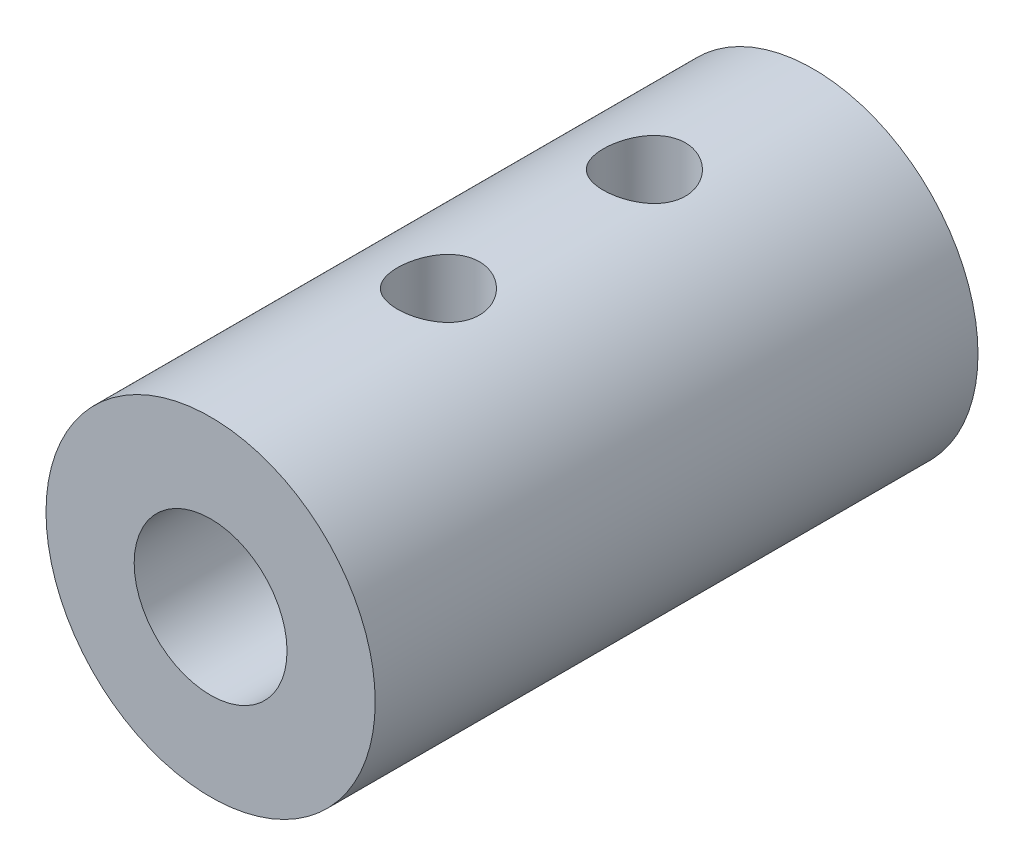
from build123d import *

# Parameters (mm, degrees)
SKETCH1_R                = 5.6
SKETCH1_R_2              = 2.6
BOSS_EXTRUDE1_DEPTH      = 11.508
BOSS_EXTRUDE1_DEPTH_BACK = 9
SKETCH3_R                = 1.397
CUT_EXTRUDE2_DEPTH       = 6.6


with BuildPart() as part:
    # Sketch1 → Boss-Extrude1 (new body, two sides)
    with BuildSketch(Plane.XY) as boss_extrude1_sk:
        Circle(SKETCH1_R)
        Circle(SKETCH1_R_2, mode=Mode.SUBTRACT)
    extrude(amount=BOSS_EXTRUDE1_DEPTH)
    extrude(boss_extrude1_sk.sketch, amount=-BOSS_EXTRUDE1_DEPTH_BACK)

    # Sketch3 → Cut-Extrude2 (cut, through all)
    with BuildSketch(Plane(origin=(0, 0, 0), x_dir=(1, 0, 0), z_dir=(0, 1, 0))):
        with Locations((0, -3.758)):
            Circle(SKETCH3_R)
        with Locations((0, 3.25)):
            Circle(SKETCH3_R)
    extrude(amount=CUT_EXTRUDE2_DEPTH, mode=Mode.SUBTRACT)


solid = part.part
